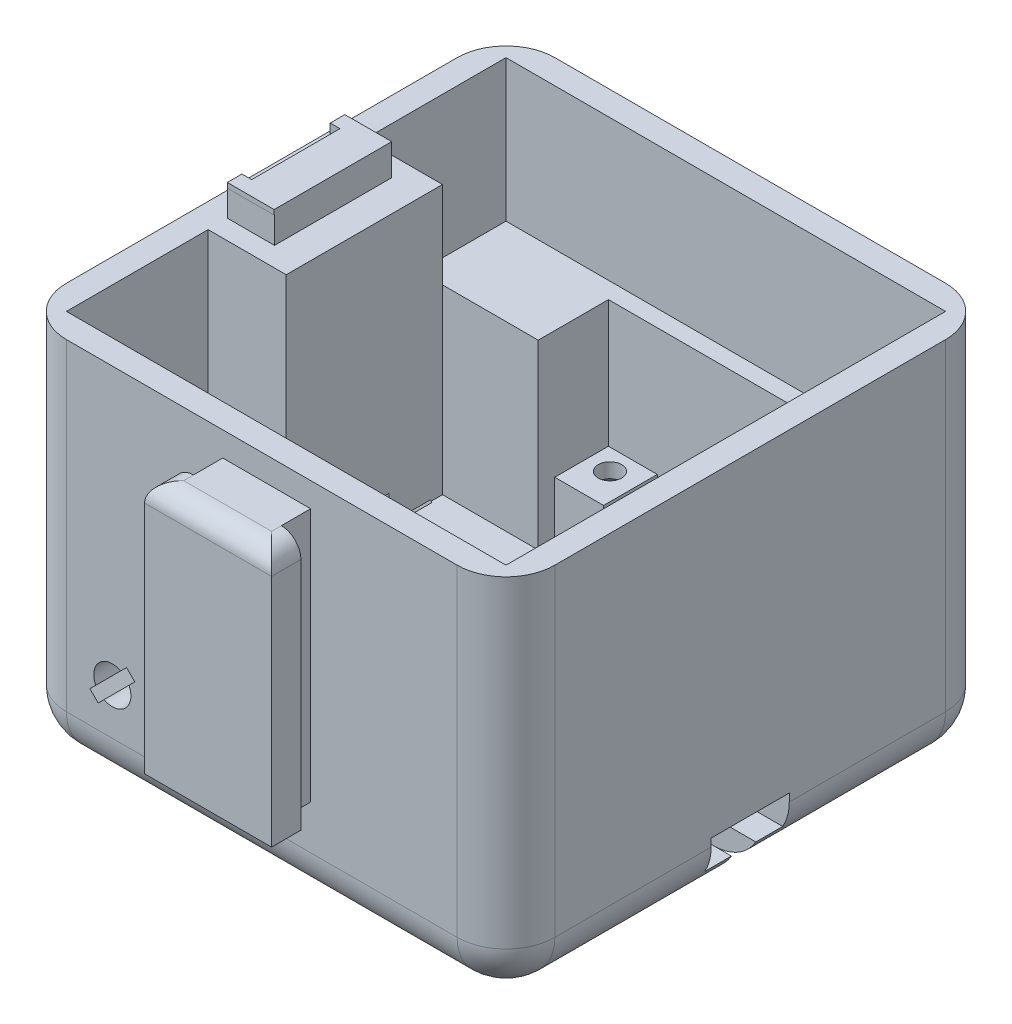
from build123d import *

# Parameters (mm, degrees)
SKETCH1_W                           = 50
SKETCH1_H                           = 50
BASE_SHELL_DEPTH                    = 38
SHELL1_T                            = -2.5
FILLET1_R                           = 5
SKETCH2_W                           = 13
SKETCH2_H                           = 26
LOCK_CONNECTOR_EXTRUDE_DEPTH        = 6
SKETCH3_W                           = 3
SKETCH3_H                           = 2
LOCK_CONNECTOR_CUT_DEPTH            = 54.350257731
LOCK_CONNECTOR_FILLET_R             = 2
SKETCH8_W                           = 45
SKETCH8_H                           = 16
BOTTOM_CONNECTOR_INSIDE_DEPTH       = 8
SKETCH10_W                          = 35.5
SKETCH10_H                          = 9.5
BOTTOM_FEMALE_BOTTOM_CUT_DEPTH      = 2.6
SKETCH7_W                           = 35.5
SKETCH7_H                           = 13.5
BOTTOM_FEMALE_TOP_CUT_DEPTH         = 3.2
ROUNDED_ENTRANCE_REACH              = 59.854
ROUNDED_ENTRANCE_DIRECTION_2_REACH  = 59.854
SKETCH22_W                          = 8
SKETCH22_H                          = 3.3
HEADER_PIN_CUT_DEPTH                = 61.541308212
HEADER_PIN_HOLDER_REACH             = 57.045
SKETCH23_W                          = 14.435585072
SKETCH23_H                          = 2.5
SKETCH25_W                          = 2
SKETCH25_H                          = 3.1
WIRE_CUT_DEPTH                      = 52.21367005
SKETCH57_W                          = 1
SKETCH57_H                          = 2.45
PIN_STOPPER_DEPTH                   = 1
SKETCH15_W                          = 16
SKETCH15_H                          = 27.5
SIDE_CONNECTOR_INSIDE_DEPTH         = 8
SKETCH58_W                          = 3.3
SKETCH58_H                          = 8
SIDE_POGO_GAP_DEPTH                 = 54.350257731
SKETCH60_W                          = 8
SKETCH60_H                          = 2.5
SIDE_POGO_SUPPORT_DEPTH             = 0.5
SERVO_HOLDER_DEPTH                  = 21
SKETCH18_W                          = 5
SKETCH18_H                          = 5.5
SCREW_HOLDERS_DEPTH                 = 8
BOTTOM_SCREW_MIRROR_COPY_1_SKETCH_W = 5
BOTTOM_SCREW_MIRROR_COPY_1_SKETCH_H = 5.5
BOTTOM_SCREW_MIRROR_COPY_1_DEPTH    = 8
SKETCH14_R                          = 1.25
LOCK_BOTTOM_SUPPORT_DEPTH           = 4.5
LOCK_CUT_DEPTH                      = 19.5
SKETCH11_R                          = 3.75
SPRING_GAP_DEPTH                    = 20
FLANG_GAP_DEPTH                     = 19
FLANG_SCREW_CUT_DEPTH               = 2.5
FILLET2_R                           = 5
SKETCH59_W                          = 5.3
SKETCH59_H                          = 8
BOTTOM_POGO_SUPPORT_DEPTH           = 0.5
SKETCH62_W                          = 6.8
SKETCH62_H                          = 12
SKETCH62_W_2                        = 2.8
SKETCH62_H_2                        = 8
SIDE_POGO_HOLDER_DEPTH              = 2.7
SKETCH63_W                          = 6.8
SKETCH63_H                          = 12.036243668
SIDE_POGO_TOP_DEPTH                 = 0.5
SIDE_START                          = -3.2
SKETCH64_W                          = 3
SKETCH64_H                          = 9.036243668
SIDE_POGO_HOLE_DEPTH                = 3.2
SKETCH65_W                          = 2
SKETCH65_H                          = 1.5
CUT_EXTRUDE8_DEPTH                  = 3.2


with BuildPart() as part:
    # Sketch1 → base shell (new body)
    with BuildSketch(Plane(origin=(0, 0, 0), x_dir=(1, 0, 0), z_dir=(0, 1, 0))):
        Rectangle(SKETCH1_W, SKETCH1_H)
    extrude(amount=BASE_SHELL_DEPTH)

    # Shell1
    shell1_openings = [part.faces().sort_by_distance(p)[0] for p in [
        (0, 38, 0),
    ]]
    offset(amount=SHELL1_T, openings=shell1_openings, kind=Kind.INTERSECTION)

    # Fillet1
    fillet1_edges = [part.edges().sort_by_distance(p)[0] for p in [
        (0, 0, -25),
        (25, 0, 0),
        (0, 0, 25),
        (-25, 0, 0),
        (-25, 19, -25),
        (25, 19, -25),
        (25, 19, 25),
        (-25, 19, 25),
    ]]
    fillet(fillet1_edges, radius=FILLET1_R)

    # Sketch2 → lock connector extrude (add)
    with BuildSketch(Plane.XY.offset(25)):
        with Locations((0.5, 22.5)):
            Rectangle(SKETCH2_W, SKETCH2_H)
    extrude(amount=LOCK_CONNECTOR_EXTRUDE_DEPTH)

    # Sketch3 → lock connector cut (cut, through all)
    with BuildSketch(Plane(origin=(0, 35.5, 0), x_dir=(0, 0, -1), z_dir=(0, 1, 0))):
        with Locations((-26.5, -6)):
            Rectangle(SKETCH3_W, SKETCH3_H)
        with Locations((-26.5, 5)):
            Rectangle(SKETCH3_W, SKETCH3_H)
    extrude(amount=-LOCK_CONNECTOR_CUT_DEPTH, mode=Mode.SUBTRACT)

    # lock connector fillet
    lock_connector_fillet_edges = [part.edges().sort_by_distance(p)[0] for p in [
        (7, 35.5, 29.5),
        (-6, 35.5, 29.5),
        (0.5, 35.5, 31),
    ]]
    fillet(lock_connector_fillet_edges, radius=LOCK_CONNECTOR_FILLET_R)

    # Sketch8 → bottom connector inside (add)
    with BuildSketch(Plane(origin=(0, 2.5, 0), x_dir=(1, 0, 0), z_dir=(0, 1, 0))):
        Rectangle(SKETCH8_W, SKETCH8_H)
    extrude(amount=BOTTOM_CONNECTOR_INSIDE_DEPTH)

    # Sketch10 → bottom female bottom cut (cut)
    with BuildSketch(Plane.XZ):
        with Locations((-7.25, 0)):
            Rectangle(SKETCH10_W, SKETCH10_H)
    bottom_female_bottom_cut = extrude(amount=-BOTTOM_FEMALE_BOTTOM_CUT_DEPTH, mode=Mode.SUBTRACT)

    # Sketch7 → bottom female top cut (cut)
    with BuildSketch(Plane(origin=(0, 2.6, 0), x_dir=(-1, 0, 0), z_dir=(0, -1, 0))):
        with Locations((7.25, 0)):
            Rectangle(SKETCH7_W, SKETCH7_H)
    bottom_female_top_cut = extrude(amount=-BOTTOM_FEMALE_TOP_CUT_DEPTH, mode=Mode.SUBTRACT)

    # rounded entrance: up to this face of the body (flat: up to its plane)
    rounded_entrance_end = Plane(part.part.faces().sort_by_distance((-7.175733888, 4.204259527, -6.75))[0])
    # Sketch26 → rounded entrance (cut, up to the picked face)
    with BuildSketch(Plane.XY.offset(-4.75), mode=Mode.PRIVATE) as rounded_entrance_sk1:
        with BuildLine():
            Line((-16, 2.6), (-24.38634244, 2.6))
            ThreePointArc((-24.38634244, 2.6), (-22.549509757, 0.698837366), (-20, 0))
            Line((-20, 0), (-18.5, 0))
            ThreePointArc((-18.5, 0), (-17.773607635, 1.80346888), (-16, 2.6))
        make_face()
    rounded_entrance_tool1 = split(extrude(rounded_entrance_sk1.sketch, amount=-ROUNDED_ENTRANCE_REACH, mode=Mode.PRIVATE), bisect_by=rounded_entrance_end, keep=Keep.BOTH, mode=Mode.PRIVATE)
    rounded_entrance = rounded_entrance_tool1.solids().sort_by(Axis((-20.596969, 1.517539, -4.75), (0, 0, -1)))[0]
    add(rounded_entrance, mode=Mode.SUBTRACT)

    # rounded entrance direction 2: up to this face of the body (flat: up to its plane)
    rounded_entrance_direction_2_end = Plane(part.part.faces().sort_by_distance((-7.175733888, 4.204259527, 6.75))[0])
    # Sketch26 → rounded entrance direction 2 (cut, up to the picked face)
    with BuildSketch(Plane.XY.offset(-4.75), mode=Mode.PRIVATE) as rounded_entrance_direction_2_sk1:
        with BuildLine():
            Line((-16, 2.6), (-24.38634244, 2.6))
            ThreePointArc((-24.38634244, 2.6), (-22.549509757, 0.698837366), (-20, 0))
            Line((-20, 0), (-18.5, 0))
            ThreePointArc((-18.5, 0), (-17.773607635, 1.80346888), (-16, 2.6))
        make_face()
    rounded_entrance_direction_2_tool1 = split(extrude(rounded_entrance_direction_2_sk1.sketch, amount=ROUNDED_ENTRANCE_DIRECTION_2_REACH, mode=Mode.PRIVATE), bisect_by=rounded_entrance_direction_2_end, keep=Keep.BOTH, mode=Mode.PRIVATE)
    rounded_entrance_direction_2 = rounded_entrance_direction_2_tool1.solids().sort_by(Axis((-20.596969, 1.517539, -4.75), (0, 0, 1)))[0]
    add(rounded_entrance_direction_2, mode=Mode.SUBTRACT)

    # Sketch22 → header pin cut (cut, through all)
    with BuildSketch(Plane.ZY.offset(-10.5)):
        with Locations((0, 4.15)):
            Rectangle(SKETCH22_W, SKETCH22_H)
    extrude(amount=-HEADER_PIN_CUT_DEPTH, mode=Mode.SUBTRACT)

    # Sketch23 → header pin holder (cut, up to next)
    with BuildSketch(Plane.XZ, mode=Mode.PRIVATE) as header_pin_holder_sk1:
        with Locations((17.717792536, 0)):
            Rectangle(SKETCH23_W, SKETCH23_H)
    header_pin_holder_tool1 = extrude(header_pin_holder_sk1.sketch, amount=-HEADER_PIN_HOLDER_REACH, mode=Mode.PRIVATE) & part.part
    add(header_pin_holder_tool1.solids().sort_by_distance((17.717793, 0, 0))[0], mode=Mode.SUBTRACT)

    # Sketch25 → wire cut (cut, through all)
    with BuildSketch(Plane(origin=(0, 5.8, 0), x_dir=(-1, 0, 0), z_dir=(0, -1, 0))):
        with Locations((-16.5, 0)):
            Rectangle(SKETCH25_W, SKETCH25_H)
    extrude(amount=-WIRE_CUT_DEPTH, mode=Mode.SUBTRACT)

    # Sketch57 → pin stopper (add)
    with BuildSketch(Plane.XZ.offset(-5.8)):
        with Locations((16.3, 2.775)):
            Rectangle(SKETCH57_W, SKETCH57_H)
        with Locations((16.3, -2.775)):
            Rectangle(SKETCH57_W, SKETCH57_H)
    extrude(amount=PIN_STOPPER_DEPTH)

    # Sketch15 → side connector inside (add)
    with BuildSketch(Plane(origin=(-22.5, 0, 0), x_dir=(0, 0, -1), z_dir=(1, 0, 0))):
        with Locations((0, 24.25)):
            Rectangle(SKETCH15_W, SKETCH15_H)
    extrude(amount=SIDE_CONNECTOR_INSIDE_DEPTH)

    # side connector mirror: bottom female bottom cut, bottom female top cut, rounded entrance, rounded entrance direction 2 across plane
    add(bottom_female_bottom_cut.mirror(Plane(origin=(-12.5, 12.5, 0), x_dir=(0, 0, 1), z_dir=(0.7071067811865488, -0.7071067811865464, 0))), mode=Mode.SUBTRACT)
    add(bottom_female_top_cut.mirror(Plane(origin=(-12.5, 12.5, 0), x_dir=(0, 0, 1), z_dir=(0.7071067811865488, -0.7071067811865464, 0))), mode=Mode.SUBTRACT)
    add(rounded_entrance.mirror(Plane(origin=(-12.5, 12.5, 0), x_dir=(0, 0, 1), z_dir=(0.7071067811865488, -0.7071067811865464, 0))), mode=Mode.SUBTRACT)
    add(rounded_entrance_direction_2.mirror(Plane(origin=(-12.5, 12.5, 0), x_dir=(0, 0, 1), z_dir=(0.7071067811865488, -0.7071067811865464, 0))), mode=Mode.SUBTRACT)

    # Sketch58 → side pogo gap (cut, through all)
    with BuildSketch(Plane.XZ.offset(-35.5)):
        with Locations((-20.85, 0)):
            Rectangle(SKETCH58_W, SKETCH58_H)
    extrude(amount=-SIDE_POGO_GAP_DEPTH, mode=Mode.SUBTRACT)

    # Sketch60 → side pogo support (add)
    with BuildSketch(Plane.ZY.offset(19.2)):
        with Locations((0, 36.75)):
            Rectangle(SKETCH60_W, SKETCH60_H)
    extrude(amount=SIDE_POGO_SUPPORT_DEPTH)

    # Sketch17 → servo holder (add)
    with BuildSketch(Plane(origin=(0, 2.5, 0), x_dir=(1, 0, 0), z_dir=(0, 1, 0))):
        Polygon((22.5, -8), (10.3, -8), (10.3, -13.5), (-10.3, -13.5), (-10.3, -8), (-22.5, -8), (-22.5, -22.5), (22.5, -22.5), align=None)
        Polygon((-22.5, 13.6), (-10.3, 13.6), (-10.3, 20.79), (10.3, 20.79), (10.3, 13.6), (22.5, 13.6), (22.5, 22.5), (-22.5, 22.5), align=None)
    extrude(amount=SERVO_HOLDER_DEPTH)

    # Sketch18 → screw holders (add)
    with BuildSketch(Plane(origin=(0, 2.5, 0), x_dir=(1, 0, 0), z_dir=(0, 1, 0))):
        with Locations((-7.8, 18.04)):
            Rectangle(SKETCH18_W, SKETCH18_H)
    screw_holders = extrude(amount=SCREW_HOLDERS_DEPTH)

    # Sketch21 → CSK SLOT for M2 Countersunk Flat Head Sc (revolve, cut)
    with BuildSketch(Plane(origin=(-8, 0, -18.64), x_dir=(0, 0, -1), z_dir=(1, 0, 0))):
        Polygon((0, 0), (0, 38), (1.2, 38), (1.2, 9), (2.2, 8), (2.2, 0), align=None)
    csk_slot_for_m2_countersunk_flat_head_sc = revolve(axis=Axis((-8, -6.35, -18.64), (0, 1, 0)), mode=Mode.SUBTRACT)

    # side screw mirror: screw holders, CSK SLOT for M2 Countersunk Flat Head Sc across plane
    add(screw_holders.mirror(Plane(origin=(0, 0, 0), x_dir=(0, 0, 1), z_dir=(1, 0, 0))))
    add(csk_slot_for_m2_countersunk_flat_head_sc.mirror(Plane(origin=(0, 0, 0), x_dir=(0, 0, 1), z_dir=(1, 0, 0))), mode=Mode.SUBTRACT)

    # bottom screw mirror: screw holders, CSK SLOT for M2 Countersunk Flat Head Sc across plane
    add(screw_holders.mirror(Plane.XY.offset(-3.645)))
    add(csk_slot_for_m2_countersunk_flat_head_sc.mirror(Plane.XY.offset(-3.645)), mode=Mode.SUBTRACT)

    # bottom screw mirror copy 1 sketch → bottom screw mirror copy 1 (add)
    with BuildSketch(Plane(origin=(0, 2.5, -7.29), x_dir=(-1, 0, 0), z_dir=(0, 1, 0))):
        with Locations((-7.8, 18.04)):
            Rectangle(BOTTOM_SCREW_MIRROR_COPY_1_SKETCH_W, BOTTOM_SCREW_MIRROR_COPY_1_SKETCH_H)
    extrude(amount=BOTTOM_SCREW_MIRROR_COPY_1_DEPTH)

    # bottom screw mirror copy 2 sketch → bottom screw mirror copy 2 (revolve, cut)
    with BuildSketch(Plane(origin=(8, 0, 11.35), x_dir=(0, 0, 1), z_dir=(-1, 0, 0))):
        Polygon((0, 0), (0, 38), (1.2, 38), (1.2, 9), (2.2, 8), (2.2, 0), align=None)
    revolve(axis=Axis((8, -6.35, 11.35), (0, 1, 0)), mode=Mode.SUBTRACT)

    # Sketch14 → Lock bottom support (add)
    with BuildSketch(Plane.XY.offset(-6.75)):
        with Locations((-15.3, 9.7)):
            Circle(SKETCH14_R)
    extrude(amount=LOCK_BOTTOM_SUPPORT_DEPTH)

    # Sketch6 → lock cut (cut)
    with BuildSketch(Plane.XY.offset(25)):
        with BuildLine():
            ThreePointArc((-16.15049081, 8.000981053), (-16.643502884, 8.356497116), (-16.999018947, 8.84950919))
            Line((-16.999018947, 8.84950919), (-17.600059711, 8.248468426))
            Line((-17.600059711, 8.248468426), (-16.751531574, 7.399940289))
            Line((-16.751531574, 7.399940289), (-16.15049081, 8.000981053))
        make_face()
        with BuildLine():
            ThreePointArc((-14.44950919, 11.399018947), (-13.956497116, 11.043502884), (-13.600981053, 10.55049081))
            Line((-13.600981053, 10.55049081), (-12.999940289, 11.151531574))
            Line((-12.999940289, 11.151531574), (-13.848468426, 12.000059711))
            Line((-13.848468426, 12.000059711), (-14.44950919, 11.399018947))
        make_face()
        with BuildLine():
            ThreePointArc((-13.4, 9.7), (-13.4509278, 10.136957664), (-13.600981053, 10.55049081))
            ThreePointArc((-13.600981053, 10.55049081), (-13.956497116, 11.043502884), (-14.44950919, 11.399018947))
            ThreePointArc((-14.44950919, 11.399018947), (-16.643502884, 11.043502884), (-16.999018947, 8.84950919))
            ThreePointArc((-16.999018947, 8.84950919), (-16.643502884, 8.356497116), (-16.15049081, 8.000981053))
            ThreePointArc((-16.15049081, 8.000981053), (-14.301484236, 8.083532781), (-13.4, 9.7))
        make_face()
    extrude(amount=-LOCK_CUT_DEPTH, mode=Mode.SUBTRACT)

    # Sketch11 → Spring gap (cut)
    with BuildSketch(Plane.XY.offset(-2.5)):
        with Locations(Location((-15.3, 9.7, 0), (0, 0, 77.682234017))):
            Circle(SKETCH11_R)
    extrude(amount=SPRING_GAP_DEPTH, mode=Mode.SUBTRACT)

    # Sketch12 → Flang gap (cut)
    with BuildSketch(Plane.XY.offset(-2.5)):
        with BuildLine():
            Line((-15.3, 9.7), (-13.274593025, 3.523615411))
            ThreePointArc((-13.274593025, 3.523615411), (-19.63620247, 4.857753812), (-21.661609445, 11.034138401))
            Line((-21.661609445, 11.034138401), (-15.3, 9.7))
        make_face()
    extrude(amount=FLANG_GAP_DEPTH, mode=Mode.SUBTRACT)

    # Sketch52 → flang screw cut (cut)
    with BuildSketch(Plane(origin=(0, 0, 6.75), x_dir=(-1, 0, 0), z_dir=(0, 0, -1))):
        with BuildLine():
            Line((21.568994271, 7.982527778), (25, 5))
            add(Edge.make_bspline(
                [(25, 5), (26.808053779, 2.347485232), (22.598490609, -3.321737418), (20, 0)],
                knots=[0, 0, 0, 0, 1, 1, 1, 1], degree=3))
            Line((20, 0), (17.017472222, 3.431005729))
            Line((17.017472222, 3.431005729), (21.568994271, 7.982527778))
        make_face()
    extrude(amount=-FLANG_SCREW_CUT_DEPTH, mode=Mode.SUBTRACT)

    # Fillet2
    fillet2_edges = [part.edges().sort_by_distance(p)[0] for p in [
        (-19.2, 5.8, -4.625),
    ]]
    fillet(fillet2_edges, radius=FILLET2_R)

    # Sketch59 → bottom pogo support (add)
    with BuildSketch(Plane.XZ.offset(-5.8)):
        with Locations((13.15, 0)):
            Rectangle(SKETCH59_W, SKETCH59_H)
    extrude(amount=BOTTOM_POGO_SUPPORT_DEPTH)

    # Sketch62 → side pogo holder (add)
    with BuildSketch(Plane(origin=(0, 38, 0), x_dir=(1, 0, 0), z_dir=(0, 1, 0))):
        with Locations((-21.1, 0)):
            Rectangle(SKETCH62_W, SKETCH62_H)
        with Locations((-21.1, 0)):
            Rectangle(SKETCH62_W_2, SKETCH62_H_2, mode=Mode.SUBTRACT)
    extrude(amount=SIDE_POGO_HOLDER_DEPTH)

    # Sketch63 → side pogo top (add)
    with BuildSketch(Plane(origin=(0, 40.7, 0), x_dir=(1, 0, 0), z_dir=(0, 1, 0))):
        with Locations((-21.1, -0.018121834)):
            Rectangle(SKETCH63_W, SKETCH63_H)
    extrude(amount=SIDE_POGO_TOP_DEPTH)

    # Sketch64 → side pogo hole (cut)
    with BuildSketch(Plane(origin=(0, 41.2, 0), x_dir=(1, 0, 0), z_dir=(0, 1, 0)).offset(SIDE_START)):
        with Locations((-23, -0.018121834)):
            Rectangle(SKETCH64_W, SKETCH64_H)
    extrude(amount=SIDE_POGO_HOLE_DEPTH, mode=Mode.SUBTRACT)

    # Sketch65 → Cut-Extrude8 (cut)
    with BuildSketch(Plane(origin=(0, 41.2, 0), x_dir=(1, 0, 0), z_dir=(0, 1, 0))):
        with Locations((-23.5, -5.286243668)):
            Rectangle(SKETCH65_W, SKETCH65_H)
        with Locations((-23.5, 5.25)):
            Rectangle(SKETCH65_W, SKETCH65_H)
    extrude(amount=-CUT_EXTRUDE8_DEPTH, mode=Mode.SUBTRACT)


solid = part.part
